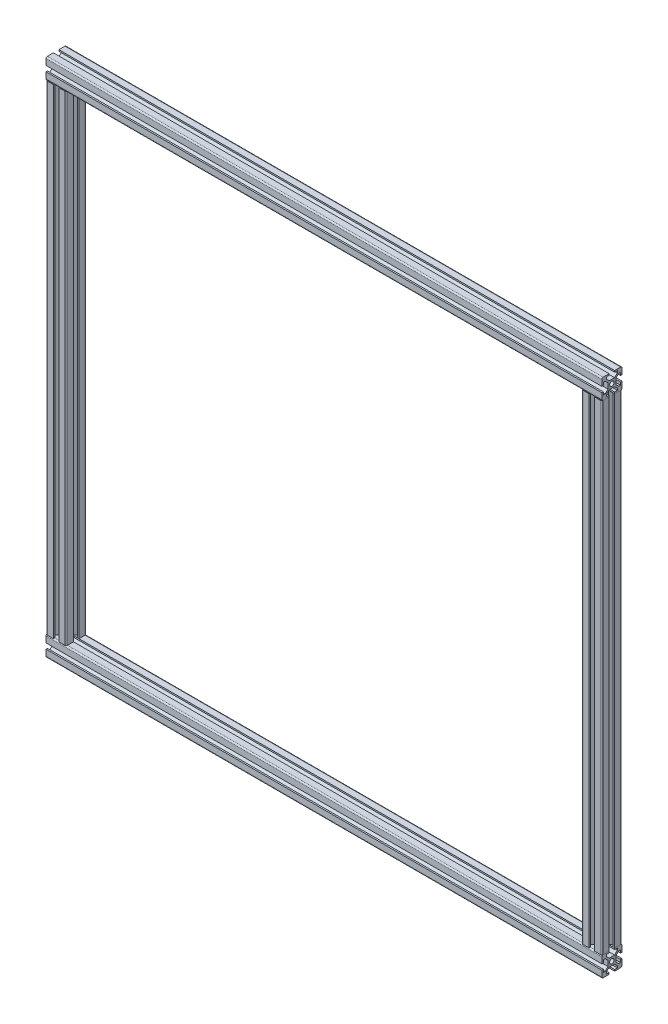
from build123d import *

# Parameters (mm, degrees)
SKETCH21_R                  = 3.325
F_4040_3030_EX_1_DEPTH      = 813
F_4040_3030_EX_1_DEPTH_BACK = 15
SKETCH21_ON_SEGMENT_2_R     = 3.325
F_4040_3030_EX_1_2_DEPTH    = 828
SKETCH21_ON_SEGMENT_3_R     = 3.325
F_4040_3030_EX_1_3_DEPTH    = 747
SKETCH21_ON_SEGMENT_4_R     = 3.325
F_4040_3030_EX_1_4_DEPTH    = 747


with BuildPart() as part:
    # Sketch21 → 4040 3030_EX(1) (new, two sides)
    with BuildSketch(Plane(origin=(798, 745, 0), x_dir=(0, 0, 1), z_dir=(-1, 0, 0))) as f_4040_3030_ex_1_sk:
        with BuildLine():
            Line((4.023948776, 5.82), (-4.023948776, 5.82))
            Line((-4.023948776, 5.82), (-8.255, 10.051051224))
            Line((-8.255, 10.051051224), (-8.255, 12.79))
            Line((-8.255, 12.79), (-4.065, 12.79))
            Line((-4.065, 12.79), (-4.065, 15))
            Line((-4.065, 15), (-13, 15))
            ThreePointArc((-13, 15), (-14.414213562, 14.414213562), (-15, 13))
            Line((-15, 13), (-15, 4.065))
            Line((-15, 4.065), (-12.79, 4.065))
            Line((-12.79, 4.065), (-12.79, 8.255))
            Line((-12.79, 8.255), (-10.051051224, 8.255))
            Line((-10.051051224, 8.255), (-5.82, 4.023948776))
            Line((-5.82, 4.023948776), (-5.82, -4.023948776))
            Line((-5.82, -4.023948776), (-10.051051224, -8.255))
            Line((-10.051051224, -8.255), (-12.79, -8.255))
            Line((-12.79, -8.255), (-12.79, -4.065))
            Line((-12.79, -4.065), (-15, -4.065))
            Line((-15, -4.065), (-15, -13))
            ThreePointArc((-15, -13), (-14.414213562, -14.414213562), (-13, -15))
            Line((-13, -15), (-4.065, -15))
            Line((-4.065, -15), (-4.065, -12.79))
            Line((-4.065, -12.79), (-8.255, -12.79))
            Line((-8.255, -12.79), (-8.255, -10.051051224))
            Line((-8.255, -10.051051224), (-4.023948776, -5.82))
            Line((-4.023948776, -5.82), (4.023948776, -5.82))
            Line((4.023948776, -5.82), (8.255, -10.051051224))
            Line((8.255, -10.051051224), (8.255, -12.79))
            Line((8.255, -12.79), (4.065, -12.79))
            Line((4.065, -12.79), (4.065, -15))
            Line((4.065, -15), (13, -15))
            ThreePointArc((13, -15), (14.414213562, -14.414213562), (15, -13))
            Line((15, -13), (15, -4.065))
            Line((15, -4.065), (12.79, -4.065))
            Line((12.79, -4.065), (12.79, -8.255))
            Line((12.79, -8.255), (10.051051224, -8.255))
            Line((10.051051224, -8.255), (5.82, -4.023948776))
            Line((5.82, -4.023948776), (5.82, 4.023948776))
            Line((5.82, 4.023948776), (10.051051224, 8.255))
            Line((10.051051224, 8.255), (12.79, 8.255))
            Line((12.79, 8.255), (12.79, 4.065))
            Line((12.79, 4.065), (15, 4.065))
            Line((15, 4.065), (15, 13))
            ThreePointArc((15, 13), (14.414213562, 14.414213562), (13, 15))
            Line((13, 15), (4.065, 15))
            Line((4.065, 15), (4.065, 12.79))
            Line((4.065, 12.79), (8.255, 12.79))
            Line((8.255, 12.79), (8.255, 10.051051224))
            Line((8.255, 10.051051224), (4.023948776, 5.82))
        make_face()
        Circle(SKETCH21_R, mode=Mode.SUBTRACT)
    extrude(amount=F_4040_3030_EX_1_DEPTH)
    extrude(f_4040_3030_ex_1_sk.sketch, amount=-F_4040_3030_EX_1_DEPTH_BACK)


with BuildPart() as body_2:
    # Sketch21 on segment 2 (carried to segment 2) → 4040 3030_EX_1 2 (new body)
    with BuildSketch(Plane.ZY.offset(-813)):
        with BuildLine():
            Line((4.023948776, 5.82), (-4.023948776, 5.82))
            Line((-4.023948776, 5.82), (-8.255, 10.051051224))
            Line((-8.255, 10.051051224), (-8.255, 12.79))
            Line((-8.255, 12.79), (-4.065, 12.79))
            Line((-4.065, 12.79), (-4.065, 15))
            Line((-4.065, 15), (-13, 15))
            ThreePointArc((-13, 15), (-14.414213562, 14.414213562), (-15, 13))
            Line((-15, 13), (-15, 4.065))
            Line((-15, 4.065), (-12.79, 4.065))
            Line((-12.79, 4.065), (-12.79, 8.255))
            Line((-12.79, 8.255), (-10.051051224, 8.255))
            Line((-10.051051224, 8.255), (-5.82, 4.023948776))
            Line((-5.82, 4.023948776), (-5.82, -4.023948776))
            Line((-5.82, -4.023948776), (-10.051051224, -8.255))
            Line((-10.051051224, -8.255), (-12.79, -8.255))
            Line((-12.79, -8.255), (-12.79, -4.065))
            Line((-12.79, -4.065), (-15, -4.065))
            Line((-15, -4.065), (-15, -13))
            ThreePointArc((-15, -13), (-14.414213562, -14.414213562), (-13, -15))
            Line((-13, -15), (-4.065, -15))
            Line((-4.065, -15), (-4.065, -12.79))
            Line((-4.065, -12.79), (-8.255, -12.79))
            Line((-8.255, -12.79), (-8.255, -10.051051224))
            Line((-8.255, -10.051051224), (-4.023948776, -5.82))
            Line((-4.023948776, -5.82), (4.023948776, -5.82))
            Line((4.023948776, -5.82), (8.255, -10.051051224))
            Line((8.255, -10.051051224), (8.255, -12.79))
            Line((8.255, -12.79), (4.065, -12.79))
            Line((4.065, -12.79), (4.065, -15))
            Line((4.065, -15), (13, -15))
            ThreePointArc((13, -15), (14.414213562, -14.414213562), (15, -13))
            Line((15, -13), (15, -4.065))
            Line((15, -4.065), (12.79, -4.065))
            Line((12.79, -4.065), (12.79, -8.255))
            Line((12.79, -8.255), (10.051051224, -8.255))
            Line((10.051051224, -8.255), (5.82, -4.023948776))
            Line((5.82, -4.023948776), (5.82, 4.023948776))
            Line((5.82, 4.023948776), (10.051051224, 8.255))
            Line((10.051051224, 8.255), (12.79, 8.255))
            Line((12.79, 8.255), (12.79, 4.065))
            Line((12.79, 4.065), (15, 4.065))
            Line((15, 4.065), (15, 13))
            ThreePointArc((15, 13), (14.414213562, 14.414213562), (13, 15))
            Line((13, 15), (4.065, 15))
            Line((4.065, 15), (4.065, 12.79))
            Line((4.065, 12.79), (8.255, 12.79))
            Line((8.255, 12.79), (8.255, 10.051051224))
            Line((8.255, 10.051051224), (4.023948776, 5.82))
        make_face()
        Circle(SKETCH21_ON_SEGMENT_2_R, mode=Mode.SUBTRACT)
    extrude(amount=F_4040_3030_EX_1_2_DEPTH)


with BuildPart() as body_3:
    # Sketch21 on segment 3 (carried to segment 3) → 4040 3030_EX_1 3 (new body)
    with BuildSketch(Plane(origin=(0, 746, 0), x_dir=(0, 0, 1), z_dir=(0, -1, 0))):
        with BuildLine():
            Line((4.023948776, 5.82), (-4.023948776, 5.82))
            Line((-4.023948776, 5.82), (-8.255, 10.051051224))
            Line((-8.255, 10.051051224), (-8.255, 12.79))
            Line((-8.255, 12.79), (-4.065, 12.79))
            Line((-4.065, 12.79), (-4.065, 15))
            Line((-4.065, 15), (-13, 15))
            ThreePointArc((-13, 15), (-14.414213562, 14.414213562), (-15, 13))
            Line((-15, 13), (-15, 4.065))
            Line((-15, 4.065), (-12.79, 4.065))
            Line((-12.79, 4.065), (-12.79, 8.255))
            Line((-12.79, 8.255), (-10.051051224, 8.255))
            Line((-10.051051224, 8.255), (-5.82, 4.023948776))
            Line((-5.82, 4.023948776), (-5.82, -4.023948776))
            Line((-5.82, -4.023948776), (-10.051051224, -8.255))
            Line((-10.051051224, -8.255), (-12.79, -8.255))
            Line((-12.79, -8.255), (-12.79, -4.065))
            Line((-12.79, -4.065), (-15, -4.065))
            Line((-15, -4.065), (-15, -13))
            ThreePointArc((-15, -13), (-14.414213562, -14.414213562), (-13, -15))
            Line((-13, -15), (-4.065, -15))
            Line((-4.065, -15), (-4.065, -12.79))
            Line((-4.065, -12.79), (-8.255, -12.79))
            Line((-8.255, -12.79), (-8.255, -10.051051224))
            Line((-8.255, -10.051051224), (-4.023948776, -5.82))
            Line((-4.023948776, -5.82), (4.023948776, -5.82))
            Line((4.023948776, -5.82), (8.255, -10.051051224))
            Line((8.255, -10.051051224), (8.255, -12.79))
            Line((8.255, -12.79), (4.065, -12.79))
            Line((4.065, -12.79), (4.065, -15))
            Line((4.065, -15), (13, -15))
            ThreePointArc((13, -15), (14.414213562, -14.414213562), (15, -13))
            Line((15, -13), (15, -4.065))
            Line((15, -4.065), (12.79, -4.065))
            Line((12.79, -4.065), (12.79, -8.255))
            Line((12.79, -8.255), (10.051051224, -8.255))
            Line((10.051051224, -8.255), (5.82, -4.023948776))
            Line((5.82, -4.023948776), (5.82, 4.023948776))
            Line((5.82, 4.023948776), (10.051051224, 8.255))
            Line((10.051051224, 8.255), (12.79, 8.255))
            Line((12.79, 8.255), (12.79, 4.065))
            Line((12.79, 4.065), (15, 4.065))
            Line((15, 4.065), (15, 13))
            ThreePointArc((15, 13), (14.414213562, 14.414213562), (13, 15))
            Line((13, 15), (4.065, 15))
            Line((4.065, 15), (4.065, 12.79))
            Line((4.065, 12.79), (8.255, 12.79))
            Line((8.255, 12.79), (8.255, 10.051051224))
            Line((8.255, 10.051051224), (4.023948776, 5.82))
        make_face()
        Circle(SKETCH21_ON_SEGMENT_3_R, mode=Mode.SUBTRACT)
    extrude(amount=F_4040_3030_EX_1_3_DEPTH)

    # 4040 3030_EX_1 3 end butt 1
    split(bisect_by=Plane.XZ.offset(-730), keep=Keep.TOP)

    # 4040 3030_EX_1 3 end butt 2
    split(bisect_by=Plane(origin=(0, 15, 0), x_dir=(-1, 0, 0), z_dir=(0, 1, 0)), keep=Keep.TOP)


with BuildPart() as body_4:
    # Sketch21 on segment 4 (carried to segment 4) → 4040 3030_EX_1 4 (new body)
    with BuildSketch(Plane(origin=(798, -1, 0), x_dir=(0, 0, 1), z_dir=(0, 1, 0))):
        with BuildLine():
            Line((4.023948776, 5.82), (-4.023948776, 5.82))
            Line((-4.023948776, 5.82), (-8.255, 10.051051224))
            Line((-8.255, 10.051051224), (-8.255, 12.79))
            Line((-8.255, 12.79), (-4.065, 12.79))
            Line((-4.065, 12.79), (-4.065, 15))
            Line((-4.065, 15), (-13, 15))
            ThreePointArc((-13, 15), (-14.414213562, 14.414213562), (-15, 13))
            Line((-15, 13), (-15, 4.065))
            Line((-15, 4.065), (-12.79, 4.065))
            Line((-12.79, 4.065), (-12.79, 8.255))
            Line((-12.79, 8.255), (-10.051051224, 8.255))
            Line((-10.051051224, 8.255), (-5.82, 4.023948776))
            Line((-5.82, 4.023948776), (-5.82, -4.023948776))
            Line((-5.82, -4.023948776), (-10.051051224, -8.255))
            Line((-10.051051224, -8.255), (-12.79, -8.255))
            Line((-12.79, -8.255), (-12.79, -4.065))
            Line((-12.79, -4.065), (-15, -4.065))
            Line((-15, -4.065), (-15, -13))
            ThreePointArc((-15, -13), (-14.414213562, -14.414213562), (-13, -15))
            Line((-13, -15), (-4.065, -15))
            Line((-4.065, -15), (-4.065, -12.79))
            Line((-4.065, -12.79), (-8.255, -12.79))
            Line((-8.255, -12.79), (-8.255, -10.051051224))
            Line((-8.255, -10.051051224), (-4.023948776, -5.82))
            Line((-4.023948776, -5.82), (4.023948776, -5.82))
            Line((4.023948776, -5.82), (8.255, -10.051051224))
            Line((8.255, -10.051051224), (8.255, -12.79))
            Line((8.255, -12.79), (4.065, -12.79))
            Line((4.065, -12.79), (4.065, -15))
            Line((4.065, -15), (13, -15))
            ThreePointArc((13, -15), (14.414213562, -14.414213562), (15, -13))
            Line((15, -13), (15, -4.065))
            Line((15, -4.065), (12.79, -4.065))
            Line((12.79, -4.065), (12.79, -8.255))
            Line((12.79, -8.255), (10.051051224, -8.255))
            Line((10.051051224, -8.255), (5.82, -4.023948776))
            Line((5.82, -4.023948776), (5.82, 4.023948776))
            Line((5.82, 4.023948776), (10.051051224, 8.255))
            Line((10.051051224, 8.255), (12.79, 8.255))
            Line((12.79, 8.255), (12.79, 4.065))
            Line((12.79, 4.065), (15, 4.065))
            Line((15, 4.065), (15, 13))
            ThreePointArc((15, 13), (14.414213562, 14.414213562), (13, 15))
            Line((13, 15), (4.065, 15))
            Line((4.065, 15), (4.065, 12.79))
            Line((4.065, 12.79), (8.255, 12.79))
            Line((8.255, 12.79), (8.255, 10.051051224))
            Line((8.255, 10.051051224), (4.023948776, 5.82))
        make_face()
        Circle(SKETCH21_ON_SEGMENT_4_R, mode=Mode.SUBTRACT)
    extrude(amount=F_4040_3030_EX_1_4_DEPTH)

    # 4040 3030_EX_1 4 end butt 1
    split(bisect_by=Plane(origin=(798, 15, 0), x_dir=(-1, 0, 0), z_dir=(0, 1, 0)), keep=Keep.TOP)

    # 4040 3030_EX_1 4 end butt 2
    split(bisect_by=Plane(origin=(798, 730, 0), x_dir=(1, 0, 0), z_dir=(0, -1, 0)), keep=Keep.TOP)


solid = Compound([part.part, body_2.part, body_3.part, body_4.part])
